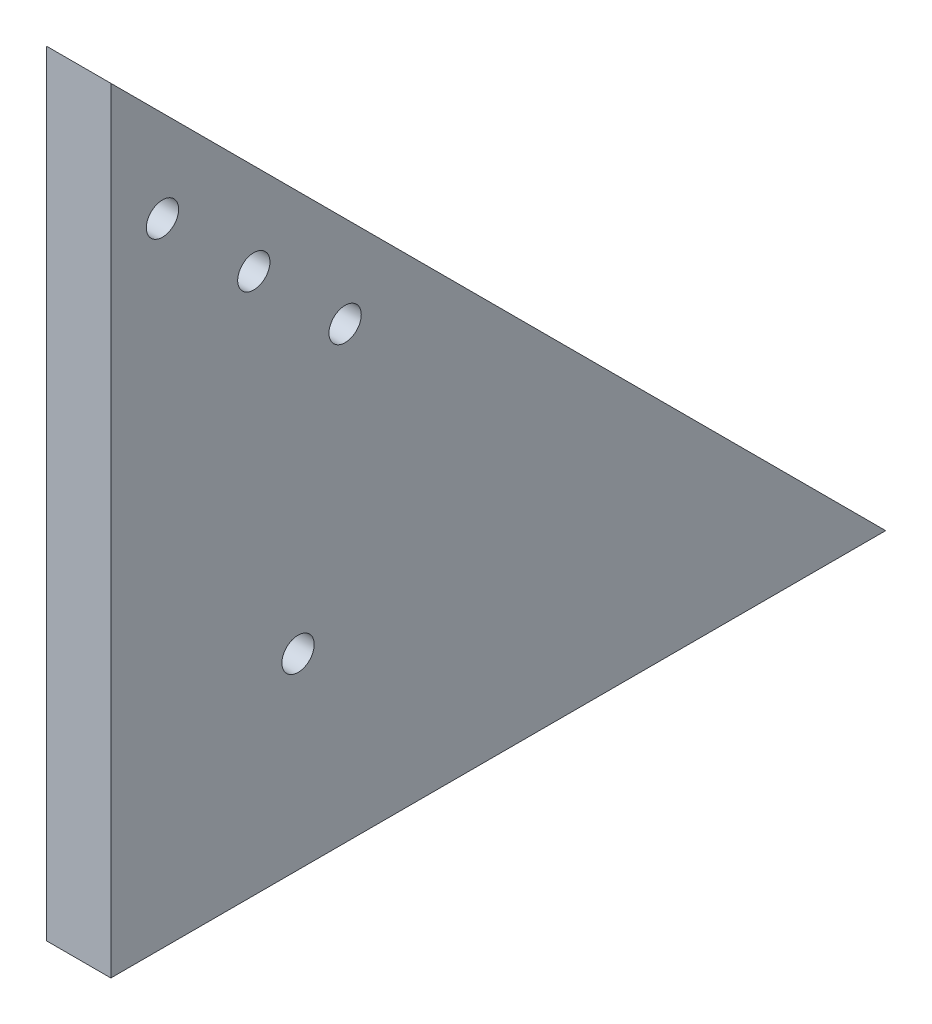
from build123d import *

# Parameters (mm, degrees)
BOSS_EXTRUDE1_DEPTH = 10
SKETCH4_R           = 2.5
CUT_EXTRUDE3_DEPTH  = 10


with BuildPart() as part:
    # Sketch1 → Boss-Extrude1 (new body)
    with BuildSketch(Plane(origin=(0, 0, 0), x_dir=(0, 0, -1), z_dir=(1, 0, 0))):
        Polygon((0, 0), (0, 120), (120, 0), align=None)
    extrude(amount=BOSS_EXTRUDE1_DEPTH)

    # Sketch4 → Cut-Extrude3 (cut)
    with BuildSketch(Plane(origin=(10, 0, 0), x_dir=(0, 0, -1), z_dir=(1, 0, 0))):
        with Locations((22.137235802, 83.720628574)):
            Circle(SKETCH4_R)
        with Locations((36.279371426, 69.578492951)):
            Circle(SKETCH4_R)
        with Locations((7.995100178, 97.862764198)):
            Circle(SKETCH4_R)
        with Locations((28.991378029, 28.991378029)):
            Circle(SKETCH4_R)
    extrude(amount=-CUT_EXTRUDE3_DEPTH, mode=Mode.SUBTRACT)


solid = part.part
